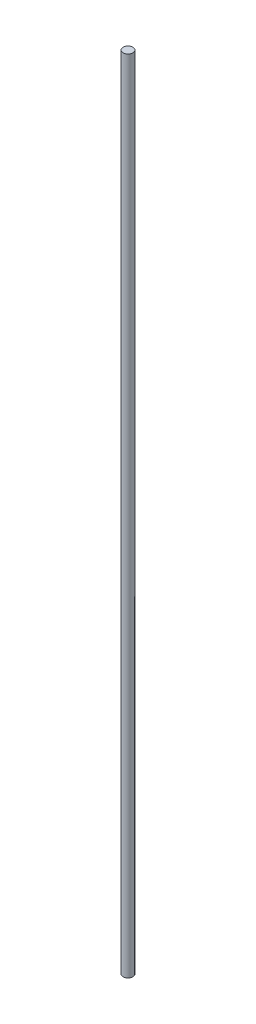
from build123d import *

# Parameters (mm, degrees)
CROQUIS1_R = 6.35


with BuildPart() as part:
    # Barrer1: sweep along a path in Croquis2
    with BuildLine(Plane.XY) as barrer1_path:
        Line((0, 0), (0, 1040))
    # Croquis1 → Barrer1 (sweep)
    with BuildSketch(Plane(origin=(0, 0, 0), x_dir=(1, 0, 0), z_dir=(0, 1, 0))):
        Circle(CROQUIS1_R)
    sweep(path=barrer1_path.line)


solid = part.part
